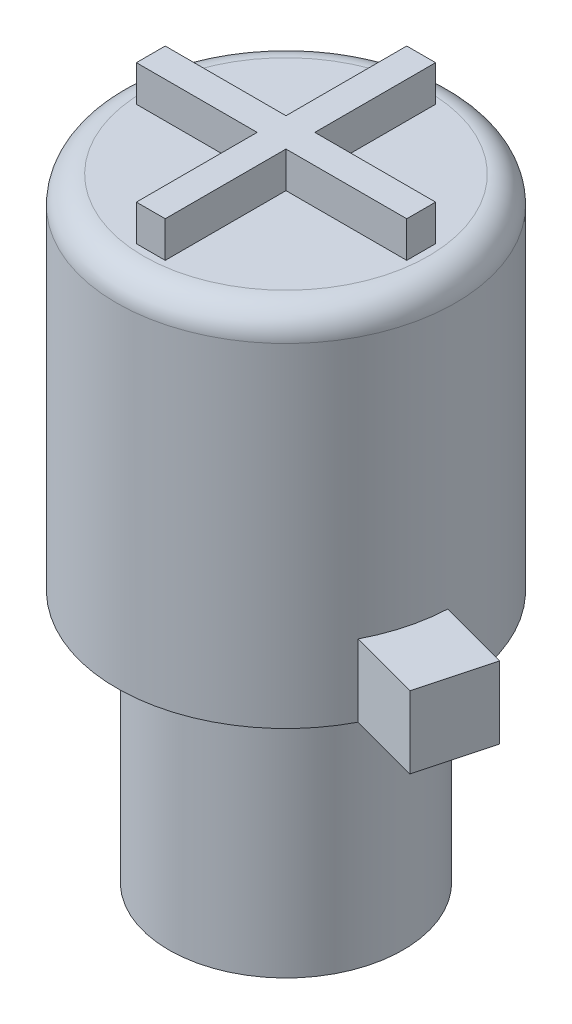
from build123d import *

# Parameters (mm, degrees)
SKETCH1_R           = 3.25
BOSS_EXTRUDE1_DEPTH = 7.018
SKETCH6_R           = 4.7
BOSS_EXTRUDE2_DEPTH = 10
BOSS_EXTRUDE3_DEPTH = 1
FILLET1_R           = 0.75
BOSS_EXTRUDE4_DEPTH = 2


with BuildPart() as part:
    # Sketch1 → Boss-Extrude1 (new body)
    with BuildSketch(Plane(origin=(0, 0, 0), x_dir=(1, 0, 0), z_dir=(0, 1, 0))):
        Circle(SKETCH1_R)
    extrude(amount=BOSS_EXTRUDE1_DEPTH)

    # Sketch6 → Boss-Extrude2 (add)
    with BuildSketch(Plane(origin=(0, 7.018, 0), x_dir=(1, 0, 0), z_dir=(0, 1, 0))):
        Circle(SKETCH6_R)
    extrude(amount=BOSS_EXTRUDE2_DEPTH)

    # Sketch8 → Boss-Extrude3 (add)
    with BuildSketch(Plane(origin=(0, 17.018, 0), x_dir=(1, 0, 0), z_dir=(0, 1, 0))):
        Polygon((0.4, 3.75), (-0.4, 3.75), (-0.4, 0.4), (-3.75, 0.4), (-3.75, -0.4), (-0.4, -0.4), (-0.4, -3.75), (0.4, -3.75), (0.4, -0.4), (3.75, -0.4), (3.75, 0.4), (0.4, 0.4), align=None)
    extrude(amount=BOSS_EXTRUDE3_DEPTH)

    # Fillet1
    fillet1_edges = [part.edges().sort_by_distance(p)[0] for p in [
        (-4.7, 17.018, 0),
    ]]
    fillet(fillet1_edges, radius=FILLET1_R)

    # Sketch10 → Boss-Extrude4 (add)
    with BuildSketch(Plane.XZ.offset(-7.018)):
        with BuildLine():
            Line((4.169549594, 2.169068046), (6.132310873, 2.694988345))
            Line((6.132310873, 2.694988345), (6.658231172, 0.732227066))
            Line((6.658231172, 0.732227066), (4.695469893, 0.206306767))
            ThreePointArc((4.695469893, 0.206306767), (4.539851384, 1.216449512), (4.169549594, 2.169068046))
        make_face()
        with BuildLine():
            Line((-4.677844754, 0.45581625), (-6.640606033, -0.07010405))
            Line((-6.640606033, -0.07010405), (-5.785985547, -3.259591128))
            Line((-5.785985547, -3.259591128), (-3.823224268, -2.733670829))
            ThreePointArc((-3.823224268, -2.733670829), (-4.539851384, -1.216449512), (-4.677844754, 0.45581625))
        make_face()
    extrude(amount=-BOSS_EXTRUDE4_DEPTH)


solid = part.part
